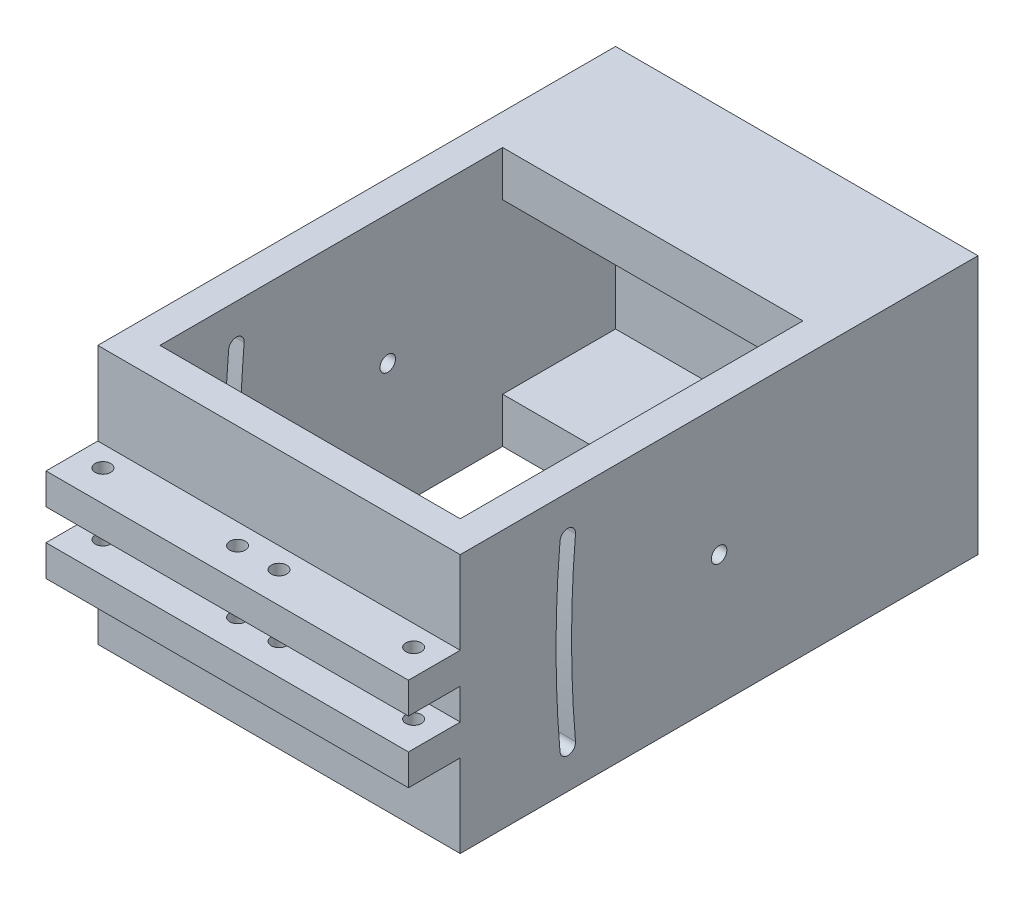
from build123d import *

# Parameters (mm, degrees)
SKETCH1_W                        = 70
SKETCH1_H                        = 100
SKETCH1_W_2                      = 58
SKETCH1_H_2                      = 88
MAIN_BODY_DEPTH                  = 50
BACK_WIRE_HOLE_REACH             = 102
SKETCH3_R                        = 1.5
FRONT_WIRE_HOLE_REACH            = 102
SKETCH6_R                        = 1.5
SKETCH4_W                        = 70
SKETCH4_H                        = 6
BACK_LIP_DEPTH                   = 10
SKETCH5_R                        = 1.5
BACK_LIP_HOLES_DEPTH             = 35
SKETCH2_R                        = 1.5
GEARED_ARM_HOLE_DEPTH            = 6
SKETCH10_W                       = 23
SKETCH10_H                       = 8.7393957
SERVO_MOUNT_MAIN_EXTRUSION_DEPTH = 58
WING_CONNECTION_SLOT_DEPTH       = 6


with BuildPart() as part:
    # Sketch1 → main_body (new body)
    with BuildSketch(Plane(origin=(0, 0, 0), x_dir=(1, 0, 0), z_dir=(0, 1, 0))):
        with Locations((0, -1.59009009)):
            Rectangle(SKETCH1_W, SKETCH1_H)
        with Locations((0, -1.59009009)):
            Rectangle(SKETCH1_W_2, SKETCH1_H_2, mode=Mode.SUBTRACT)
    extrude(amount=MAIN_BODY_DEPTH)

    # Sketch3 → back_wire_hole (cut, up to next)
    with BuildSketch(Plane.XY.offset(51.59009009), mode=Mode.PRIVATE) as back_wire_hole_sk1:
        with Locations((0, 25)):
            Circle(SKETCH3_R)
    back_wire_hole_tool1 = extrude(back_wire_hole_sk1.sketch, amount=-BACK_WIRE_HOLE_REACH, mode=Mode.PRIVATE) & part.part
    add(back_wire_hole_tool1.solids().sort_by_distance((0, 25, 51.59009))[0], mode=Mode.SUBTRACT)

    # Sketch6 → front_wire_hole (cut, up to next)
    with BuildSketch(Plane(origin=(0, 0, -48.40990991), x_dir=(-1, 0, 0), z_dir=(0, 0, -1)), mode=Mode.PRIVATE) as front_wire_hole_sk1:
        with Locations((0, 25)):
            Circle(SKETCH6_R)
    front_wire_hole_tool1 = extrude(front_wire_hole_sk1.sketch, amount=-FRONT_WIRE_HOLE_REACH, mode=Mode.PRIVATE) & part.part
    add(front_wire_hole_tool1.solids().sort_by_distance((0, 25, -48.40991))[0], mode=Mode.SUBTRACT)

    # Sketch4 → back_lip (add)
    with BuildSketch(Plane.XY.offset(51.59009009)):
        with Locations((0, 31)):
            Rectangle(SKETCH4_W, SKETCH4_H)
    back_lip = extrude(amount=BACK_LIP_DEPTH)

    # back_lip_mirror: back_lip across plane
    add(back_lip.mirror(Plane.ZX.offset(25)))

    # Sketch5 → back_lip_holes (cut, through all)
    with BuildSketch(Plane(origin=(0, 34, 0), x_dir=(1, 0, 0), z_dir=(0, 1, 0))):
        with Locations((4, -55.59009009)):
            Circle(SKETCH5_R)
        with Locations((30, -55.59009009)):
            Circle(SKETCH5_R)
        with Locations((-30, -55.59009009)):
            Circle(SKETCH5_R)
        with Locations((-4, -55.59009009)):
            Circle(SKETCH5_R)
    extrude(amount=-BACK_LIP_HOLES_DEPTH, mode=Mode.SUBTRACT)

    # Sketch2 → geared_arm_hole (cut)
    with BuildSketch(Plane(origin=(35, 0, 0), x_dir=(0, 0, -1), z_dir=(1, 0, 0))):
        with Locations((-1.59009009, 25)):
            Circle(SKETCH2_R)
    geared_arm_hole = extrude(amount=-GEARED_ARM_HOLE_DEPTH, mode=Mode.SUBTRACT)

    # geared_arm_hole_mirror: geared_arm_hole across plane
    add(geared_arm_hole.mirror(Plane(origin=(0, 0, 0), x_dir=(0, 0, 1), z_dir=(1, 0, 0))), mode=Mode.SUBTRACT)

    # Sketch10 → servo_mount_main_extrusion (add)
    with BuildSketch(Plane(origin=(-29, 0, 0), x_dir=(0, 0, -1), z_dir=(1, 0, 0))):
        with Locations((32.100688533, 4.36969785)):
            Rectangle(SKETCH10_W, SKETCH10_H)
        with Locations((32.100688533, 45.63030215)):
            Rectangle(SKETCH10_W, SKETCH10_H)
    extrude(amount=SERVO_MOUNT_MAIN_EXTRUSION_DEPTH)

    # Sketch11 → wing_connection_slot (cut)
    with BuildSketch(Plane(origin=(35, 0, 0), x_dir=(0, 0, -1), z_dir=(1, 0, 0))):
        with BuildLine():
            ThreePointArc((-32.317240778, 42.63125), (-33.09009009, 25), (-32.317240778, 7.36875))
            ThreePointArc((-32.317240778, 7.36875), (-30.691743999, 6.005753221), (-29.32874722, 7.63125))
            ThreePointArc((-29.32874722, 7.63125), (-30.09009009, 25), (-29.32874722, 42.36875))
            ThreePointArc((-29.32874722, 42.36875), (-30.691743999, 43.994246779), (-32.317240778, 42.63125))
        make_face()
    wing_connection_slot = extrude(amount=-WING_CONNECTION_SLOT_DEPTH, mode=Mode.SUBTRACT)

    # wing_connection_slot_mirror: wing_connection_slot across plane
    add(wing_connection_slot.mirror(Plane(origin=(0, 0, 0), x_dir=(0, 0, 1), z_dir=(1, 0, 0))), mode=Mode.SUBTRACT)


solid = part.part
